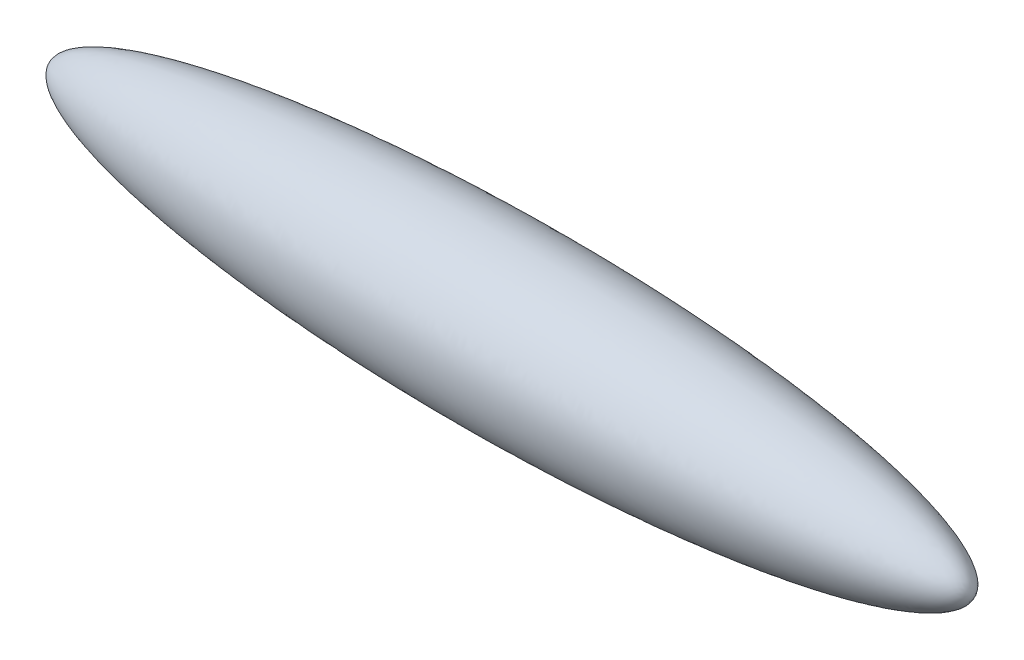
from build123d import *


with BuildPart() as part:
    # Sketch3 → Revolve7 (revolve)
    with BuildSketch(Plane.XY):
        with BuildLine():
            Line((686, 0), (-686, 0))
            add(Edge.make_bspline(
                [(-686, 0), (-685.999699841, 0.699762326), (-685.931521707, 2.094218113), (-685.55649747, 4.637965523), (-684.2628279, 8.604873746), (-681.968295878, 12.712931398), (-678.728264586, 16.796165297), (-674.290075568, 21.205508483), (-668.924248848, 25.524528376), (-663.25721873, 29.309016588), (-657.431789427, 32.698599113), (-651.39939298, 35.892192469), (-643.103479577, 39.913318056), (-631.185543211, 44.963598591), (-615.52322749, 50.653539592), (-597.1721586, 56.398452232), (-578.381515849, 61.576323633), (-558.31083984, 66.52203083), (-539.929097147, 70.583234063), (-523.288567451, 73.954123813), (-505.444364817, 77.320768374), (-487.559894738, 80.467897014), (-460.67079516, 84.821001907), (-424.713188922, 89.938965728), (-382.651255974, 95.069554192), (-334.473780951, 99.969373121), (-274.155387504, 105.048133494), (-201.660305627, 109.650376097), (-116.981559032, 113.117931931), (-32.244561215, 114.522208898), (40.393889621, 114.310672933), (100.913873713, 113.178821858), (149.315361086, 111.68676652), (197.694372146, 109.585271974), (246.041292807, 106.840204399), (294.344243629, 103.403079918), (342.587514384, 99.206138989), (390.749496573, 94.154551187), (432.792221759, 88.867500421), (468.727078308, 83.590540683), (498.578054351, 78.596447242), (522.386695381, 74.189861346), (546.101772652, 69.301956886), (566.742409683, 64.518063348), (584.323796603, 59.967267187), (598.737039083, 55.845212666), (610.029472283, 52.347214335), (621.095326866, 48.607951135), (631.908534663, 44.584171198), (642.63356268, 40.125768927), (653.192019719, 35.111962747), (663.568013972, 29.294829114), (672.447558279, 23.042881718), (679.184258235, 16.630287224), (683.293703086, 10.643601379), (685.25579529, 5.948790369), (685.880472014, 2.773755584), (685.999583238, 0.927345765), (686, 0)],
                knots=[0, 0, 0, 0, 0, 0.001961721, 0.003923442, 0.007201149, 0.011660888, 0.015093701, 0.018526514, 0.024755054, 0.030983594, 0.034221068, 0.037458543, 0.043933492, 0.056883391, 0.070574314, 0.084265237, 0.09795616, 0.111647083, 0.128656442, 0.137161121, 0.1456658, 0.162675159, 0.179684517, 0.21370325, 0.247721982, 0.281740715, 0.315759448, 0.383796911, 0.451834378, 0.519871843, 0.553890576, 0.587909308, 0.621928041, 0.655946773, 0.689965505, 0.723984238, 0.758002971, 0.792021705, 0.826040429, 0.843049791, 0.860059153, 0.877068499, 0.894077845, 0.911087191, 0.919591864, 0.928096537, 0.93620106, 0.944305583, 0.952410106, 0.960514628, 0.968826901, 0.977139174, 0.985794311, 0.990964598, 0.994801757, 0.997400879, 1, 1, 1, 1, 1], degree=4))
        make_face()
    revolve(axis=Axis((4.573905344, 0, 0), (-1, 0, 0)))


solid = part.part
